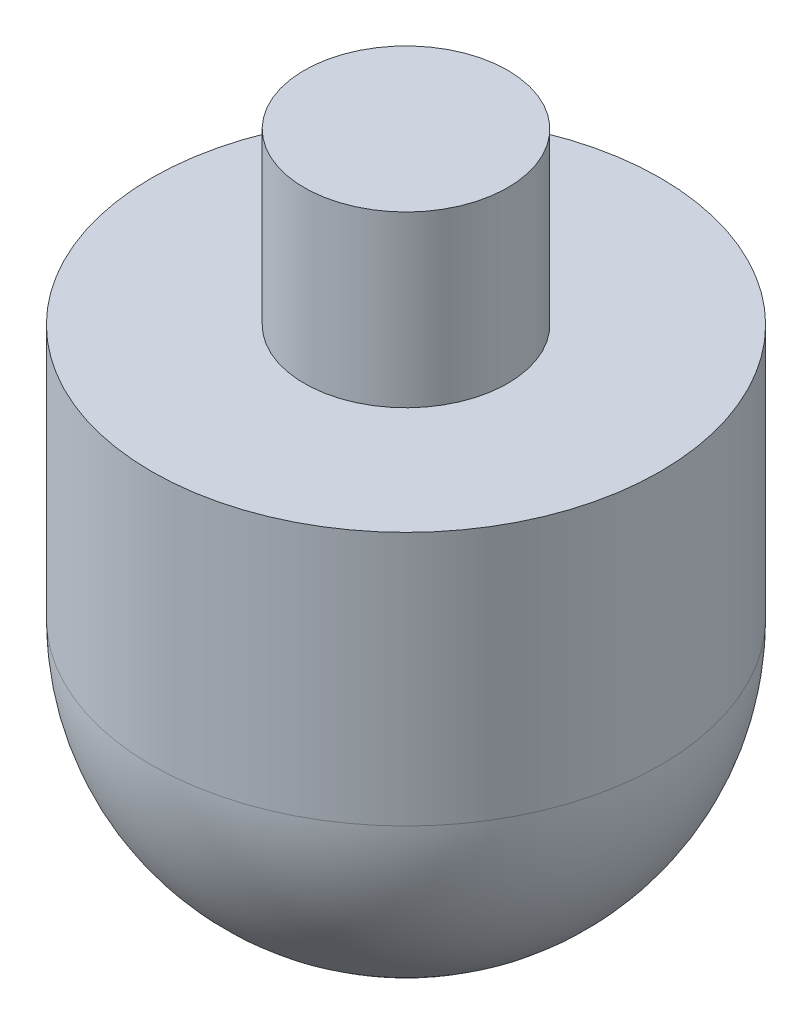
from build123d import *

# Parameters (mm, degrees)
FILLET2_R = 15


with BuildPart() as part:
    # Sketch1 → Revolve1 (revolve)
    with BuildSketch(Plane.XY, mode=Mode.PRIVATE) as revolve1_sk:
        Polygon((0, 0), (15, 0), (15, 30), (6, 30), (6, 40), (0, 40), align=None)
    revolve(revolve1_sk.sketch.rotate(Axis((0, 0, 0), (0, 1, 0)), 90), axis=Axis((0, 0, 0), (0, 1, 0)))  # turned: the seam where the file's is

    # Fillet2
    fillet2_edges = [part.edges().sort_by_distance(p)[0] for p in [
        (0, 0, 15),
    ]]
    fillet(fillet2_edges, radius=FILLET2_R)


solid = part.part
